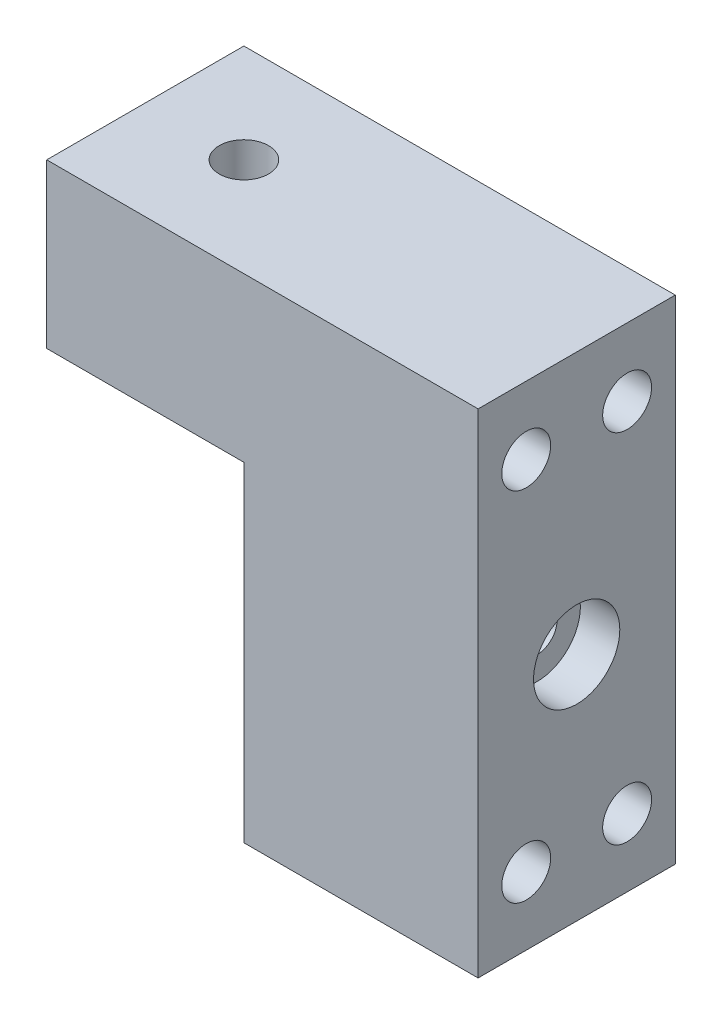
from build123d import *

# Parameters (mm, degrees)
SKETCH2_W                                           = 25.4
SKETCH2_H                                           = 63.5
BOSS_EXTRUDE1_DEPTH                                 = 30.17596
SKETCH3_W                                           = 25.4
SKETCH3_H                                           = 21.05
BOSS_EXTRUDE2_DEPTH                                 = 25.4
F_1_4_0_25_DIAMETER_HOLE1_D                         = 6.35
F_1_0MM_DOWEL_HOLE1_D                               = 6.3
F_1_0MM_DOWEL_HOLE1_DEPTH                           = 8.9916
F_1_0MM_DOWEL_HOLE1_TIP                             = 1.89271095
TAP_DRILL_FOR_5_HELICOIL0_D                         = 4
TAP_DRILL_FOR_5_HELICOIL0_DEPTH                     = 15.24
TAP_DRILL_FOR_5_HELICOIL0_TIP                       = 1.201721238
CBORE_FOR_10_BINDING_HEAD_MACHINE_SCREW_D           = 5.1054
CBORE_FOR_10_BINDING_HEAD_MACHINE_SCREW_DEPTH       = 30.17596
CBORE_FOR_10_BINDING_HEAD_MACHINE_SCREW_CBORE_D     = 11.1125
CBORE_FOR_10_BINDING_HEAD_MACHINE_SCREW_CBORE_DEPTH = 5.08


with BuildPart() as part:
    # Sketch2 → Boss-Extrude1 (new body)
    with BuildSketch(Plane(origin=(0, 0, 0), x_dir=(0, 0, -1), z_dir=(1, 0, 0))):
        with Locations((-225.049350785, -379.861725806)):
            Rectangle(SKETCH2_W, SKETCH2_H)
    extrude(amount=-BOSS_EXTRUDE1_DEPTH)

    # Sketch3 → Boss-Extrude2 (add)
    with BuildSketch(Plane.ZY.offset(30.17596)):
        with Locations((225.049350785, -358.636725806)):
            Rectangle(SKETCH3_W, SKETCH3_H)
    extrude(amount=BOSS_EXTRUDE2_DEPTH)

    # 1/4 (0.25) Diameter Hole1 (through all)
    with Locations(Plane(origin=(0, -348.111725806, 0), x_dir=(1, 0, 0), z_dir=(0, 1, 0))):
        with Locations((-42.87596, -225.049350785)):
            Hole(F_1_4_0_25_DIAMETER_HOLE1_D / 2)

    # Ø1.0mm Dowel Hole1
    with Locations(Plane(origin=(0, 0, 0), x_dir=(0, 0, -1), z_dir=(1, 0, 0))):
        with Locations((-231.549350785, -356.861725806), (-218.549350785, -356.861725806), (-218.549350785, -402.861725806), (-231.549350785, -402.861725806)):
            Hole(F_1_0MM_DOWEL_HOLE1_D / 2, depth=F_1_0MM_DOWEL_HOLE1_DEPTH)
            with Locations((0, 0, -(F_1_0MM_DOWEL_HOLE1_DEPTH + F_1_0MM_DOWEL_HOLE1_TIP / 2))):  # 118° drill point
                Cone(0, F_1_0MM_DOWEL_HOLE1_D / 2, F_1_0MM_DOWEL_HOLE1_TIP, mode=Mode.SUBTRACT)

    # Tap Drill for #5 Helicoil0
    with Locations(Plane(origin=(0, 0, 212.349350785), x_dir=(-1, 0, 0), z_dir=(0, 0, -1))):
        with Locations((9.7875, -371.924225806), (9.7875, -387.799225806)):
            Hole(TAP_DRILL_FOR_5_HELICOIL0_D / 2, depth=TAP_DRILL_FOR_5_HELICOIL0_DEPTH)
            with Locations((0, 0, -(TAP_DRILL_FOR_5_HELICOIL0_DEPTH + TAP_DRILL_FOR_5_HELICOIL0_TIP / 2))):  # 118° drill point
                Cone(0, TAP_DRILL_FOR_5_HELICOIL0_D / 2, TAP_DRILL_FOR_5_HELICOIL0_TIP, mode=Mode.SUBTRACT)

    # CBORE for #10 Binding Head Machine Screw1
    with Locations(Plane(origin=(0, 0, 0), x_dir=(0, 0, -1), z_dir=(1, 0, 0))):
        with Locations((-225.049350785, -381.861725806)):
            CounterBoreHole(CBORE_FOR_10_BINDING_HEAD_MACHINE_SCREW_D / 2, CBORE_FOR_10_BINDING_HEAD_MACHINE_SCREW_CBORE_D / 2, CBORE_FOR_10_BINDING_HEAD_MACHINE_SCREW_CBORE_DEPTH, depth=CBORE_FOR_10_BINDING_HEAD_MACHINE_SCREW_DEPTH)


solid = part.part
